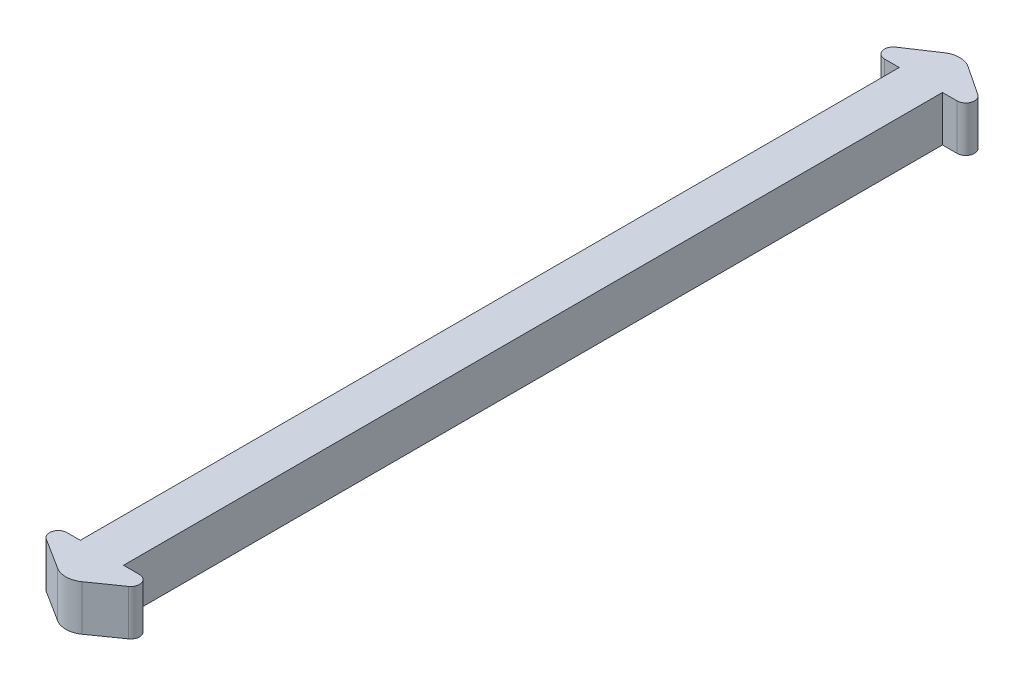
from build123d import *

# Parameters (mm, degrees)
SKETCH1_W           = 9.5
SKETCH1_H           = 180
BOSS_EXTRUDE1_DEPTH = 10
FILLET1_R           = 1.9
FILLET2_R           = 4.75


with BuildPart() as part:
    # Sketch1 → Boss-Extrude1 (new body)
    with BuildSketch(Plane(origin=(0, 0, 0), x_dir=(1, 0, 0), z_dir=(0, 1, 0))):
        with Locations((-2.027493606, -84.590792839)):
            Rectangle(SKETCH1_W, SKETCH1_H)
        Polygon((-6.777493606, 5.409207161), (-2.027493606, 5.409207161), (-2.027493606, 14.909207161), (-16.277493606, 5.409207161), align=None)
        Polygon((-2.027493606, 14.909207161), (-2.027493606, 5.409207161), (2.722506394, 5.409207161), (12.222506394, 5.409207161), align=None)
        Polygon((-6.777493606, -174.590792839), (2.722506394, -174.590792839), (12.222506394, -174.590792839), (-1.277493606, -184.090792839), (-16.277493606, -174.590792839), align=None)
    extrude(amount=BOSS_EXTRUDE1_DEPTH)

    # Fillet1
    fillet1_edges = [part.edges().sort_by_distance(p)[0] for p in [
        (12.222506394, 5, -5.409207161),
        (12.222506394, 5, 174.590792839),
        (-16.277493606, 5, 174.590792839),
        (-16.277493606, 5, -5.409207161),
    ]]
    fillet(fillet1_edges, radius=FILLET1_R)

    # Fillet2
    fillet2_edges = [part.edges().sort_by_distance(p)[0] for p in [
        (-1.277493606, 5, 184.090792839),
        (-2.027493606, 5, -14.909207161),
    ]]
    fillet(fillet2_edges, radius=FILLET2_R)


solid = part.part
